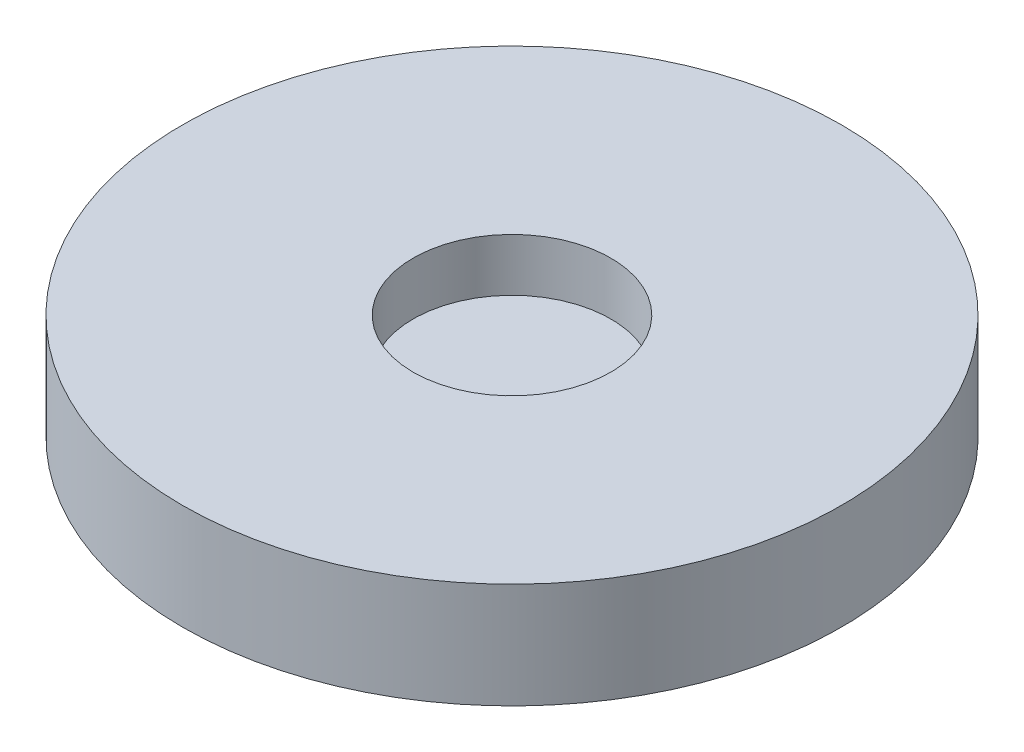
from build123d import *

# Parameters (mm, degrees)
SKETCH1_R           = 25
BOSS_EXTRUDE1_DEPTH = 8
SKETCH2_R           = 7.5
CUT_EXTRUDE1_DEPTH  = 4


with BuildPart() as part:
    # Sketch1 → Boss-Extrude1 (new body)
    with BuildSketch(Plane(origin=(0, 0, 0), x_dir=(1, 0, 0), z_dir=(0, 1, 0))):
        Circle(SKETCH1_R)
    extrude(amount=BOSS_EXTRUDE1_DEPTH)

    # Sketch2 → Cut-Extrude1 (cut)
    with BuildSketch(Plane(origin=(0, 8, 0), x_dir=(1, 0, 0), z_dir=(0, 1, 0))):
        Circle(SKETCH2_R)
    extrude(amount=-CUT_EXTRUDE1_DEPTH, mode=Mode.SUBTRACT)


solid = part.part
